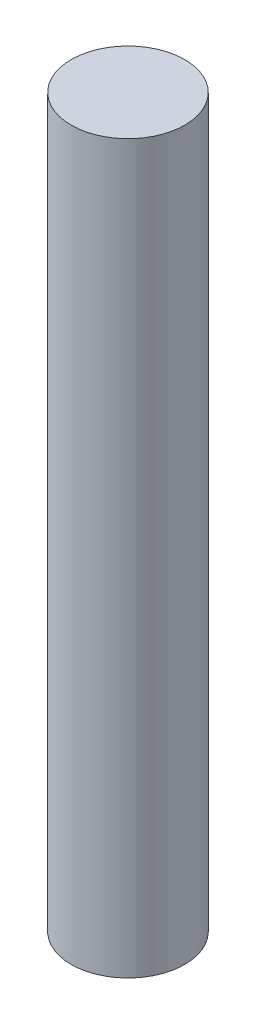
from build123d import *

# Parameters (mm, degrees)
SKETCH1_R           = 3.175
BOSS_EXTRUDE1_DEPTH = 40.64


with BuildPart() as part:
    # Sketch1 → Boss-Extrude1 (new body)
    with BuildSketch(Plane(origin=(0, 0, 0), x_dir=(1, 0, 0), z_dir=(0, 1, 0))):
        Circle(SKETCH1_R)
    extrude(amount=BOSS_EXTRUDE1_DEPTH)


solid = part.part
